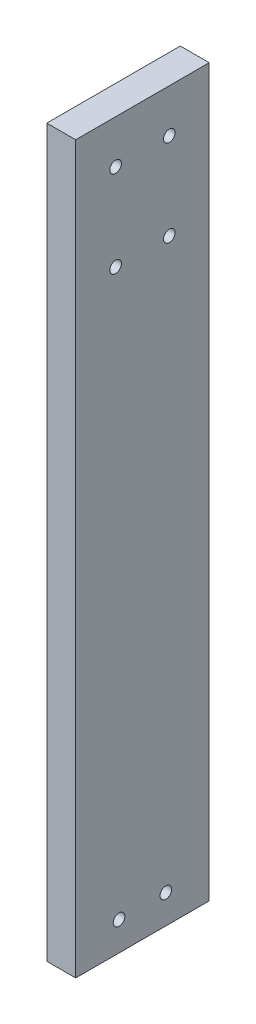
from build123d import *

# Parameters (mm, degrees)
SKETCH1_W               = 12.7
SKETCH1_H               = 58.674
BOSS_EXTRUDE1_DEPTH     = 319.024
F_1_4_20_TAPPED_HOLE1_D = 5.1054


with BuildPart() as part:
    # Sketch1 → Boss-Extrude1 (new body)
    with BuildSketch(Plane(origin=(0, 0, 0), x_dir=(1, 0, 0), z_dir=(0, 1, 0))):
        with Locations((6.35, 29.337)):
            Rectangle(SKETCH1_W, SKETCH1_H)
    extrude(amount=-BOSS_EXTRUDE1_DEPTH)

    # 1/4-20 Tapped Hole1 (through all)
    with Locations(Plane(origin=(0, -306.324, -19.05), x_dir=(0, 0, -1), z_dir=(-1, 0, 0))):
        with Locations((0, 0), (20.574, 0), (22.098, -287.274), (-1.524, -287.274), (22.098, -249.174), (-1.524, -249.174)):
            Hole(F_1_4_20_TAPPED_HOLE1_D / 2)


solid = part.part
